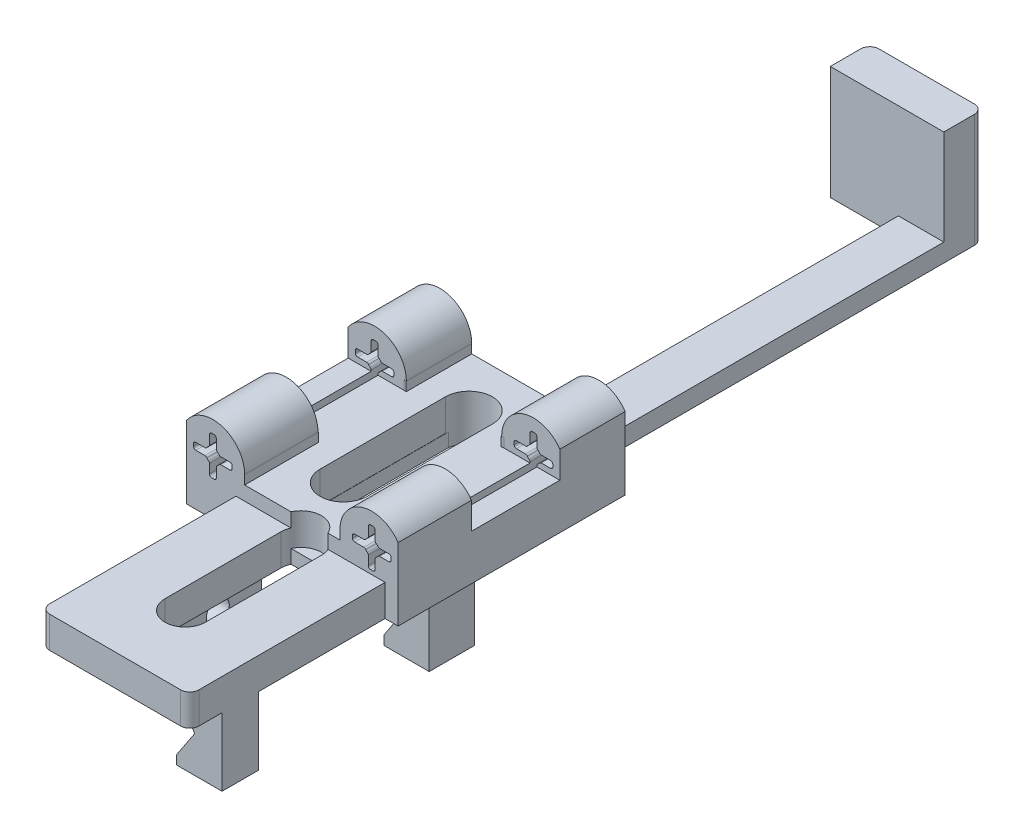
from build123d import *

# Parameters (mm, degrees)
EXTRUDE_1_DEPTH          = 50
SKETCH_3_W               = 67.092836977
SKETCH_3_H               = 19.45251838
CUT_EXTRUDE_1_DEPTH      = 10
CUT_EXTRUDE_2_DEPTH      = 12
EXTRUDE_2_DEPTH          = 43
SKETCH_7_W               = 20.970814044
SKETCH_7_H               = 50
CUT_EXTRUDE_3_DEPTH      = 12
SKETCH_10_W              = 6.123292798
SKETCH_10_H              = 19.344721243
EXTRUDE_4_DEPTH          = 18
EXTRUDE_7_DEPTH          = 85
SKETCH_17_W              = 25
SKETCH_17_H              = 8.70212247
EXTRUDE_8_DEPTH          = 25
SKETCH_18_W              = 10
SKETCH_18_H              = 10
SKETCH_18_H_2            = 8
EXTRUDE_9_DEPTH          = 18
CUT_EXTRUDE_4_DEPTH      = 200.899557275
SKETCH_20_R              = 2.529450183
CUT_EXTRUDE_5_DEPTH      = 10
CUT_EXTRUDE_6_DEPTH      = 19
CUT_EXTRUDE_6_DEPTH_BACK = 26
FILLET_9_R               = 2
FILLET_10_R              = 2
EXTRUDE_10_DEPTH         = 50
SKETCH_22_W              = 10.372741246
SKETCH_22_H              = 27.593865213
CUT_EXTRUDE_8_DEPTH      = 50
CUT_EXTRUDE_10_DEPTH     = 50
FILLET_11_R              = 2


with BuildPart() as part:
    # Эскиз1 → Бобышка-Вытянуть1 (new body)
    with BuildSketch(Plane.XY):
        with BuildLine():
            Line((13.193690737, -1.091861006), (13.193690737, -14))
            Line((13.193690737, -14), (59.788586278, -14))
            Line((59.788586278, -14), (59.788586278, -1.091861006))
            ThreePointArc((59.788586278, -1.091861006), (51.938117998, 1.695227195), (46.981138508, -5))
            Line((46.981138508, -5), (26.001138508, -5))
            ThreePointArc((26.001138508, -5), (21.044159018, 1.695227195), (13.193690737, -1.091861006))
        make_face()
        with BuildLine():
            Line((23.257720879, -4.7432839), (23.257720879, -5.2567161))
            ThreePointArc((23.257720879, -5.2567161), (23.11127427, -5.61026949), (22.757720879, -5.7567161))
            Line((22.757720879, -5.7567161), (20.745903028, -5.7567161))
            ThreePointArc((20.745903028, -5.7567161), (20.517992262, -5.811680502), (20.340189413, -5.964489369))
            ThreePointArc((20.340189413, -5.964489369), (20.168035476, -6.166896968), (19.965627876, -6.339050905))
            ThreePointArc((19.965627876, -6.339050905), (19.81281901, -6.516853754), (19.757854607, -6.74476452))
            Line((19.757854607, -6.74476452), (19.757854607, -8.756582371))
            ThreePointArc((19.757854607, -8.756582371), (19.611407998, -9.110135762), (19.257854607, -9.256582371))
            Line((19.257854607, -9.256582371), (18.744422408, -9.256582371))
            ThreePointArc((18.744422408, -9.256582371), (18.390869018, -9.110135762), (18.244422408, -8.756582371))
            Line((18.244422408, -8.756582371), (18.244422408, -6.74476452))
            ThreePointArc((18.244422408, -6.74476452), (18.189458005, -6.516853754), (18.036649139, -6.339050905))
            ThreePointArc((18.036649139, -6.339050905), (17.83424154, -6.166896968), (17.662087603, -5.964489369))
            ThreePointArc((17.662087603, -5.964489369), (17.484284754, -5.811680502), (17.256373988, -5.7567161))
            Line((17.256373988, -5.7567161), (15.244556137, -5.7567161))
            ThreePointArc((15.244556137, -5.7567161), (14.891002746, -5.61026949), (14.744556137, -5.2567161))
            Line((14.744556137, -5.2567161), (14.744556137, -4.7432839))
            ThreePointArc((14.744556137, -4.7432839), (14.891002746, -4.38973051), (15.244556137, -4.2432839))
            Line((15.244556137, -4.2432839), (17.256373988, -4.2432839))
            ThreePointArc((17.256373988, -4.2432839), (17.484284754, -4.188319498), (17.662087603, -4.035510631))
            ThreePointArc((17.662087603, -4.035510631), (17.83424154, -3.833103032), (18.036649139, -3.660949095))
            ThreePointArc((18.036649139, -3.660949095), (18.189458005, -3.483146246), (18.244422408, -3.25523548))
            Line((18.244422408, -3.25523548), (18.244422408, -1.243417629))
            ThreePointArc((18.244422408, -1.243417629), (18.390869018, -0.889864238), (18.744422408, -0.743417629))
            Line((18.744422408, -0.743417629), (19.257854607, -0.743417629))
            ThreePointArc((19.257854607, -0.743417629), (19.611407998, -0.889864238), (19.757854607, -1.243417629))
            Line((19.757854607, -1.243417629), (19.757854607, -3.25523548))
            ThreePointArc((19.757854607, -3.25523548), (19.81281901, -3.483146246), (19.965627876, -3.660949095))
            ThreePointArc((19.965627876, -3.660949095), (20.168035476, -3.833103032), (20.340189413, -4.035510631))
            ThreePointArc((20.340189413, -4.035510631), (20.517992262, -4.188319498), (20.745903028, -4.2432839))
            Line((20.745903028, -4.2432839), (22.757720879, -4.2432839))
            ThreePointArc((22.757720879, -4.2432839), (23.11127427, -4.38973051), (23.257720879, -4.7432839))
        make_face(mode=Mode.SUBTRACT)
        with BuildLine():
            ThreePointArc((58.237720879, -5.2567161), (58.09127427, -5.61026949), (57.737720879, -5.7567161))
            Line((57.737720879, -5.7567161), (55.725903028, -5.7567161))
            ThreePointArc((55.725903028, -5.7567161), (55.497992262, -5.811680502), (55.320189413, -5.964489369))
            ThreePointArc((55.320189413, -5.964489369), (55.148035476, -6.166896968), (54.945627876, -6.339050905))
            ThreePointArc((54.945627876, -6.339050905), (54.79281901, -6.516853754), (54.737854607, -6.74476452))
            Line((54.737854607, -6.74476452), (54.737854607, -8.716400411))
            Line((54.737854607, -8.716400411), (54.737753859, -8.766619212))
            ThreePointArc((54.737753859, -8.766619212), (54.58784145, -9.113666689), (54.237854607, -9.256582371))
            Line((54.237854607, -9.256582371), (53.724422408, -9.256582371))
            ThreePointArc((53.724422408, -9.256582371), (53.370869018, -9.110135762), (53.224422408, -8.756582371))
            Line((53.224422408, -8.756582371), (53.224422408, -6.74476452))
            ThreePointArc((53.224422408, -6.74476452), (53.169458005, -6.516853754), (53.016649139, -6.339050905))
            ThreePointArc((53.016649139, -6.339050905), (52.81424154, -6.166896968), (52.642087603, -5.964489369))
            ThreePointArc((52.642087603, -5.964489369), (52.464284754, -5.811680502), (52.236373988, -5.7567161))
            Line((52.236373988, -5.7567161), (50.224556137, -5.7567161))
            ThreePointArc((50.224556137, -5.7567161), (49.871002746, -5.61026949), (49.724556137, -5.2567161))
            Line((49.724556137, -5.2567161), (49.724556137, -4.7432839))
            ThreePointArc((49.724556137, -4.7432839), (49.871002746, -4.38973051), (50.224556137, -4.2432839))
            Line((50.224556137, -4.2432839), (52.236373988, -4.2432839))
            ThreePointArc((52.236373988, -4.2432839), (52.464284754, -4.188319498), (52.642087603, -4.035510631))
            ThreePointArc((52.642087603, -4.035510631), (52.81424154, -3.833103032), (53.016649139, -3.660949095))
            ThreePointArc((53.016649139, -3.660949095), (53.169458005, -3.483146246), (53.224422408, -3.25523548))
            Line((53.224422408, -3.25523548), (53.224422408, -1.243417629))
            ThreePointArc((53.224422408, -1.243417629), (53.370869018, -0.889864238), (53.724422408, -0.743417629))
            Line((53.724422408, -0.743417629), (54.237854607, -0.743417629))
            ThreePointArc((54.237854607, -0.743417629), (54.591407998, -0.889864238), (54.737854607, -1.243417629))
            Line((54.737854607, -1.243417629), (54.737854607, -3.25523548))
            ThreePointArc((54.737854607, -3.25523548), (54.79281901, -3.483146246), (54.945627876, -3.660949095))
            ThreePointArc((54.945627876, -3.660949095), (55.148035476, -3.833103032), (55.320189413, -4.035510631))
            ThreePointArc((55.320189413, -4.035510631), (55.497992262, -4.188319498), (55.725903028, -4.2432839))
            Line((55.725903028, -4.2432839), (57.737720879, -4.2432839))
            ThreePointArc((57.737720879, -4.2432839), (58.09127427, -4.38973051), (58.237720879, -4.7432839))
            Line((58.237720879, -4.7432839), (58.237720879, -5.2567161))
        make_face(mode=Mode.SUBTRACT)
    extrude(amount=EXTRUDE_1_DEPTH)

    # Эскиз3 → Вырез-Вытянуть1 (cut)
    with BuildSketch(Plane(origin=(0, 5, 0), x_dir=(1, 0, 0), z_dir=(0, 1, 0))):
        with Locations((41.003987207, -24.119131243)):
            Rectangle(SKETCH_3_W, SKETCH_3_H)
    extrude(amount=-CUT_EXTRUDE_1_DEPTH, mode=Mode.SUBTRACT)

    # Эскиз4 → Вырез-Вытянуть2 (cut)
    with BuildSketch(Plane(origin=(0, 5, 0), x_dir=(1, 0, 0), z_dir=(0, 1, 0))):
        with BuildLine():
            Line((12, -14.392872053), (25.453701909, -14.392872053))
            ThreePointArc((25.453701909, -14.392872053), (26.867915472, -14.978658491), (27.453701909, -16.392872053))
            Line((27.453701909, -16.392872053), (27.453701909, -31.845390433))
            ThreePointArc((27.453701909, -31.845390433), (26.867915472, -33.259603995), (25.453701909, -33.845390433))
            Line((25.453701909, -33.845390433), (12, -33.845390433))
            Line((12, -33.845390433), (9.423236547, -33.845390433))
            Line((9.423236547, -33.845390433), (9.423236547, -14.392872053))
            Line((9.423236547, -14.392872053), (12, -14.392872053))
        make_face()
        with BuildLine():
            Line((63.559040468, -33.845390433), (60.982277016, -33.845390433))
            Line((60.982277016, -33.845390433), (47.528575106, -33.845390433))
            ThreePointArc((47.528575106, -33.845390433), (46.114361544, -33.259603995), (45.528575106, -31.845390433))
            Line((45.528575106, -31.845390433), (45.528575106, -16.392872053))
            ThreePointArc((45.528575106, -16.392872053), (46.114361544, -14.978658491), (47.528575106, -14.392872053))
            Line((47.528575106, -14.392872053), (60.982277016, -14.392872053))
            Line((60.982277016, -14.392872053), (63.559040468, -14.392872053))
            Line((63.559040468, -14.392872053), (63.559040468, -33.845390433))
        make_face()
    extrude(amount=-CUT_EXTRUDE_2_DEPTH, mode=Mode.SUBTRACT)

    # Эскиз5 → Бобышка-Вытянуть2 (add)
    with BuildSketch(Plane.XY.offset(50)):
        Polygon((24.078896454, -14), (24.078896454, -10.1), (56.919106274, -10.1), (56.919106274, -14), (56.919106274, -17.012540358), (24.078896454, -17.012540358), align=None)
    extrude(amount=EXTRUDE_2_DEPTH)

    # Эскиз7 → Вырез-Вытянуть3 (cut)
    with BuildSketch(Plane(origin=(0, 5, 0), x_dir=(1, 0, 0), z_dir=(0, 1, 0))):
        with Locations((36.48654553, -25)):
            Rectangle(SKETCH_7_W, SKETCH_7_H)
    extrude(amount=-CUT_EXTRUDE_3_DEPTH, mode=Mode.SUBTRACT)

    # Эскиз10 → Бобышка-Вытянуть4 (add)
    with BuildSketch(Plane(origin=(0, -14, 0), x_dir=(-1, 0, 0), z_dir=(0, -1, 0))):
        with Locations((-27.140542853, -60.168867761)):
            Rectangle(SKETCH_10_W, SKETCH_10_H)
    extrude(amount=EXTRUDE_4_DEPTH)

    # Эскиз15 → Бобышка-Вытянуть7 (add)
    with BuildSketch(Plane(origin=(0, 0, 0), x_dir=(-1, 0, 0), z_dir=(0, 0, -1))):
        Polygon((-53.655904349, -10), (-53.655904349, -14), (-49.655904349, -14), (-43.655904349, -14), (-43.655904349, -10), (-49.655904349, -10), align=None)
    extrude(amount=EXTRUDE_7_DEPTH)

    # Эскиз17 → Бобышка-Вытянуть8 (add)
    with BuildSketch(Plane.XZ.offset(14)):
        with Locations((41.155904349, -80.648938765)):
            Rectangle(SKETCH_17_W, SKETCH_17_H)
    extrude(amount=-EXTRUDE_8_DEPTH)

    # Эскиз18 → Бобышка-Вытянуть9 (add)
    with BuildSketch(Plane(origin=(0, -14, 0), x_dir=(-1, 0, 0), z_dir=(0, -1, 0))):
        with Locations((-51.901619791, -35.265464626)):
            Rectangle(SKETCH_18_W, SKETCH_18_H)
        with Locations((-51.919106274, -81.899557275)):
            Rectangle(SKETCH_18_W, SKETCH_18_H_2)
    extrude(amount=EXTRUDE_9_DEPTH)

    # Эскиз19 → Вырез-Вытянуть4 (cut, through all)
    with BuildSketch(Plane.XY.offset(114.899557275)):
        Polygon((46.919106274, -30), (44.350584359, -30), (44.350584359, -18), (46.919106274, -18), (50.908701671, -24), align=None)
    extrude(amount=-CUT_EXTRUDE_4_DEPTH, mode=Mode.SUBTRACT)

    # Эскиз20 → Вырез-Вытянуть5 (cut)
    with BuildSketch(Plane.ZY.offset(-24.078896454)):
        with Locations((60.114190628, -24)):
            Circle(SKETCH_20_R)
    extrude(amount=-CUT_EXTRUDE_5_DEPTH, mode=Mode.SUBTRACT)

    # Эскиз21 → Вырез-Вытянуть6 (cut, two sides)
    with BuildSketch(Plane.XZ.offset(14)) as cut_extrude_6_sk:
        with BuildLine():
            Line((35.809150035, 77.378220879), (35.809150035, 51.851168114))
            ThreePointArc((35.809150035, 51.851168114), (40.281040372, 47.379277776), (44.75293071, 51.851168114))
            Line((44.75293071, 51.851168114), (44.75293071, 77.378220879))
            ThreePointArc((44.75293071, 77.378220879), (40.281040372, 81.850111217), (35.809150035, 77.378220879))
        make_face()
    extrude(amount=CUT_EXTRUDE_6_DEPTH, mode=Mode.SUBTRACT)
    extrude(cut_extrude_6_sk.sketch, amount=-CUT_EXTRUDE_6_DEPTH_BACK, mode=Mode.SUBTRACT)

    # Скругление9
    fillet_9_edges = [part.edges().sort_by_distance(p)[0] for p in [
        (24.078896454, -13.556270179, 93),
        (56.919106274, -13.556270179, 93),
    ]]
    fillet(fillet_9_edges, radius=FILLET_9_R)

    # Скругление10
    fillet_10_edges = [part.edges().sort_by_distance(p)[0] for p in [
        (53.655904349, -1.5, -85),
        (28.655904349, -1.5, -85),
    ]]
    fillet(fillet_10_edges, radius=FILLET_10_R)

    # Эскиз23 → Бобышка-Вытянуть10 (add)
    with BuildSketch(Plane(origin=(0, 0, 50), x_dir=(-1, 0, 0), z_dir=(0, 0, -1))):
        Polygon((-24.078896454, -17.012540358), (-13.20276963, -17.012540358), (-13.193690737, -14), (-59.788586278, -14), (-59.788586278, -17.012540358), align=None)
    extrude(amount=EXTRUDE_10_DEPTH)

    # Эскиз22 → Вырез-Вытянуть8 (cut)
    with BuildSketch(Plane.XZ.offset(14)):
        with BuildLine():
            Line((31.276507068, 38.681400317), (41.649248314, 38.681400317))
            ThreePointArc((41.649248314, 38.681400317), (36.462877691, 43.86777094), (31.276507068, 38.681400317))
        make_face()
        with Locations((36.462877691, 24.884467711)):
            Rectangle(SKETCH_22_W, SKETCH_22_H)
        with BuildLine():
            Line((41.649248314, 11.087535104), (31.276507068, 11.087535104))
            ThreePointArc((31.276507068, 11.087535104), (36.462877691, 5.901164482), (41.649248314, 11.087535104))
        make_face()
    extrude(amount=-CUT_EXTRUDE_8_DEPTH, mode=Mode.SUBTRACT)

    # Эскиз24 → Вырез-Вытянуть10 (cut)
    with BuildSketch(Plane(origin=(0, -14, 0), x_dir=(1, 0, 0), z_dir=(0, 1, 0))):
        with BuildLine():
            ThreePointArc((41.612901226, -10.474593165), (36.462877691, -5.901164482), (31.312854156, -10.474593165))
            Line((31.312854156, -10.474593165), (41.612901226, -10.474593165))
        make_face()
        with BuildLine():
            Line((41.612901226, -10.474593165), (31.312854156, -10.474593165))
            Line((31.312854156, -10.474593165), (31.312854156, -11.704802977))
            Line((31.312854156, -11.704802977), (31.312854156, -38.681400317))
            Line((31.312854156, -38.681400317), (41.649248314, -38.681400317))
            Line((41.649248314, -38.681400317), (41.649248314, -11.704802977))
            Line((41.649248314, -11.704802977), (41.649248314, -11.087535104))
            ThreePointArc((41.649248314, -11.087535104), (41.640153568, -10.780525767), (41.612901226, -10.474593165))
        make_face()
        with BuildLine():
            Line((31.312854156, -38.681400317), (41.649248314, -38.681400317))
            ThreePointArc((41.649248314, -38.681400317), (36.481051235, -43.849597396), (31.312854156, -38.681400317))
        make_face()
    extrude(amount=-CUT_EXTRUDE_10_DEPTH, mode=Mode.SUBTRACT)

    # Скругление11
    fillet_11_edges = [part.edges().sort_by_distance(p)[0] for p in [
        (27.140542853, -32, 69.841228382),
        (27.140542853, -32, 50.496507139),
    ]]
    fillet(fillet_11_edges, radius=FILLET_11_R)


solid = part.part
